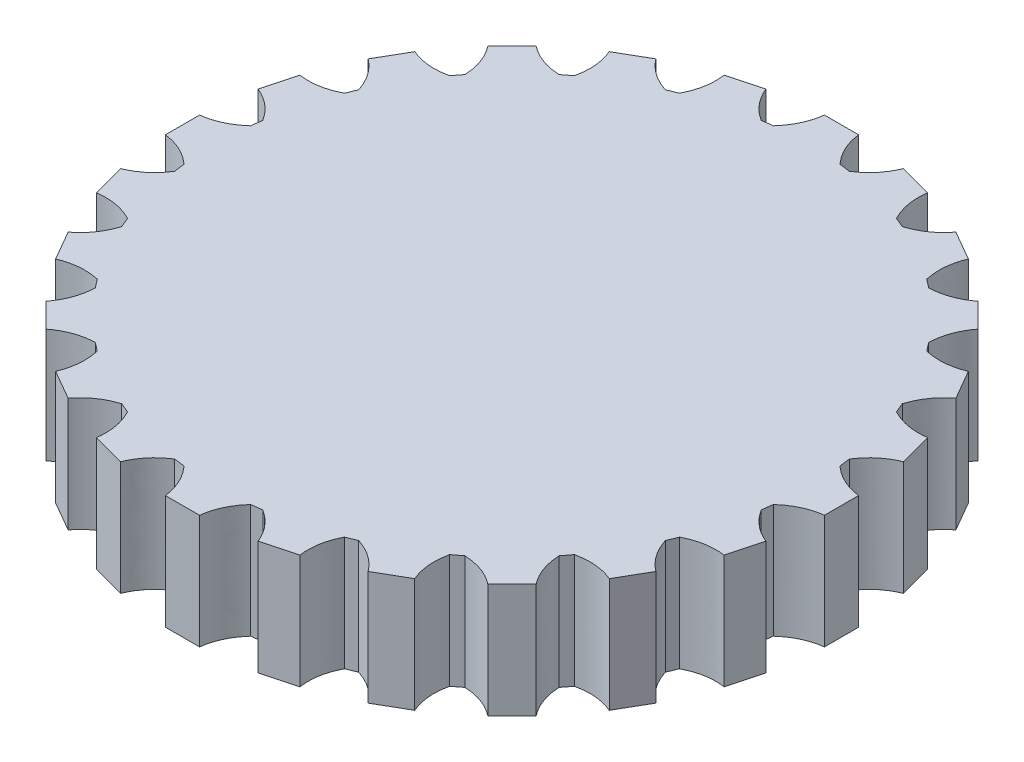
from build123d import *

# Parameters (mm, degrees)
BOSS_EXTRUDE2_DEPTH = 1.5
SKETCH3_R           = 3.8
CUT_EXTRUDE1_DEPTH  = 1.3


with BuildPart() as part:
    # Sketch2 → Boss-Extrude2 (new body)
    with BuildSketch(Plane(origin=(0, 0, 0), x_dir=(1, 0, 0), z_dir=(0, 1, 0))):
        with BuildLine():
            Line((0.224673315, 4.334046599), (-0.224673315, 4.334046599))
            add(Edge.make_bspline(
                [(-0.437962601, 3.875330794), (-0.256985034, 4.073833314), (-0.224673315, 4.334046599)],
                knots=[0, 0, 0, 1, 1, 1], degree=2))
            ThreePointArc((-0.437962601, 3.875330794), (-0.50905215, 3.866634959), (-0.579970028, 3.856635161))
            add(Edge.make_bspline(
                [(-0.579970028, 3.856635161), (-0.806157167, 4.001533431), (-0.904716044, 4.244517276)],
                knots=[0, 0, 0, 1, 1, 1], degree=2))
            Line((-0.904716044, 4.244517276), (-1.33875156, 4.12821781))
            add(Edge.make_bspline(
                [(-1.426048803, 3.629929037), (-1.302614129, 3.868508189), (-1.33875156, 4.12821781)],
                knots=[0, 0, 0, 1, 1, 1], degree=2))
            ThreePointArc((-1.426048803, 3.629929037), (-1.492465386, 3.603130177), (-1.558378658, 3.575116216))
            add(Edge.make_bspline(
                [(-1.558378658, 3.575116216), (-1.814361089, 3.656535658), (-1.972450501, 3.865731114)],
                knots=[0, 0, 0, 1, 1, 1], degree=2))
            Line((-1.972450501, 3.865731114), (-2.361596098, 3.641057799))
            add(Edge.make_bspline(
                [(-2.316952135, 3.137153615), (-2.259472225, 3.399550624), (-2.361596098, 3.641057799)],
                knots=[0, 0, 0, 1, 1, 1], degree=2))
            ThreePointArc((-2.316952135, 3.137153615), (-2.374169573, 3.094078027), (-2.430586358, 3.049959009))
            add(Edge.make_bspline(
                [(-2.430586358, 3.049959009), (-2.698919302, 3.062351022), (-2.905765716, 3.223501765)],
                knots=[0, 0, 0, 1, 1, 1], degree=2))
            Line((-2.905765716, 3.223501765), (-3.223501765, 2.905765716))
            add(Edge.make_bspline(
                [(-3.049959009, 2.430586358), (-3.062351022, 2.698919302), (-3.223501765, 2.905765716)],
                knots=[0, 0, 0, 1, 1, 1], degree=2))
            ThreePointArc((-3.049959009, 2.430586358), (-3.094078027, 2.374169573), (-3.137153615, 2.316952135))
            add(Edge.make_bspline(
                [(-3.137153615, 2.316952135), (-3.399550624, 2.259472225), (-3.641057799, 2.361596098)],
                knots=[0, 0, 0, 1, 1, 1], degree=2))
            Line((-3.641057799, 2.361596098), (-3.865731114, 1.972450501))
            add(Edge.make_bspline(
                [(-3.575116216, 1.558378658), (-3.656535658, 1.814361089), (-3.865731114, 1.972450501)],
                knots=[0, 0, 0, 1, 1, 1], degree=2))
            ThreePointArc((-3.575116216, 1.558378658), (-3.603130177, 1.492465386), (-3.629929037, 1.426048803))
            add(Edge.make_bspline(
                [(-3.629929037, 1.426048803), (-3.868508189, 1.302614129), (-4.12821781, 1.33875156)],
                knots=[0, 0, 0, 1, 1, 1], degree=2))
            Line((-4.12821781, 1.33875156), (-4.244517276, 0.904716044))
            add(Edge.make_bspline(
                [(-3.856635161, 0.579970028), (-4.001533431, 0.806157167), (-4.244517276, 0.904716044)],
                knots=[0, 0, 0, 1, 1, 1], degree=2))
            ThreePointArc((-3.856635161, 0.579970028), (-3.866634959, 0.50905215), (-3.875330794, 0.437962601))
            add(Edge.make_bspline(
                [(-3.875330794, 0.437962601), (-4.073833314, 0.256985034), (-4.334046599, 0.224673315)],
                knots=[0, 0, 0, 1, 1, 1], degree=2))
            Line((-4.334046599, 0.224673315), (-4.334046599, -0.224673315))
            add(Edge.make_bspline(
                [(-3.875330794, -0.437962601), (-4.073833314, -0.256985034), (-4.334046599, -0.224673315)],
                knots=[0, 0, 0, 1, 1, 1], degree=2))
            ThreePointArc((-3.875330794, -0.437962601), (-3.866634959, -0.50905215), (-3.856635161, -0.579970028))
            add(Edge.make_bspline(
                [(-3.856635161, -0.579970028), (-4.001533431, -0.806157167), (-4.244517276, -0.904716044)],
                knots=[0, 0, 0, 1, 1, 1], degree=2))
            Line((-4.244517276, -0.904716044), (-4.12821781, -1.33875156))
            add(Edge.make_bspline(
                [(-3.629929037, -1.426048803), (-3.868508189, -1.302614129), (-4.12821781, -1.33875156)],
                knots=[0, 0, 0, 1, 1, 1], degree=2))
            ThreePointArc((-3.629929037, -1.426048803), (-3.603130177, -1.492465386), (-3.575116216, -1.558378658))
            add(Edge.make_bspline(
                [(-3.575116216, -1.558378658), (-3.656535658, -1.814361089), (-3.865731114, -1.972450501)],
                knots=[0, 0, 0, 1, 1, 1], degree=2))
            Line((-3.865731114, -1.972450501), (-3.641057799, -2.361596098))
            add(Edge.make_bspline(
                [(-3.137153615, -2.316952135), (-3.399550624, -2.259472225), (-3.641057799, -2.361596098)],
                knots=[0, 0, 0, 1, 1, 1], degree=2))
            ThreePointArc((-3.137153615, -2.316952135), (-3.094078027, -2.374169573), (-3.049959009, -2.430586358))
            add(Edge.make_bspline(
                [(-3.049959009, -2.430586358), (-3.062351022, -2.698919302), (-3.223501765, -2.905765716)],
                knots=[0, 0, 0, 1, 1, 1], degree=2))
            Line((-3.223501765, -2.905765716), (-2.905765716, -3.223501765))
            add(Edge.make_bspline(
                [(-2.430586358, -3.049959009), (-2.698919302, -3.062351022), (-2.905765716, -3.223501765)],
                knots=[0, 0, 0, 1, 1, 1], degree=2))
            ThreePointArc((-2.430586358, -3.049959009), (-2.374169573, -3.094078027), (-2.316952135, -3.137153615))
            add(Edge.make_bspline(
                [(-2.316952135, -3.137153615), (-2.259472225, -3.399550624), (-2.361596098, -3.641057799)],
                knots=[0, 0, 0, 1, 1, 1], degree=2))
            Line((-2.361596098, -3.641057799), (-1.972450501, -3.865731114))
            add(Edge.make_bspline(
                [(-1.558378658, -3.575116216), (-1.814361089, -3.656535658), (-1.972450501, -3.865731114)],
                knots=[0, 0, 0, 1, 1, 1], degree=2))
            ThreePointArc((-1.558378658, -3.575116216), (-1.492465386, -3.603130177), (-1.426048803, -3.629929037))
            add(Edge.make_bspline(
                [(-1.426048803, -3.629929037), (-1.302614129, -3.868508189), (-1.33875156, -4.12821781)],
                knots=[0, 0, 0, 1, 1, 1], degree=2))
            Line((-1.33875156, -4.12821781), (-0.904716044, -4.244517276))
            add(Edge.make_bspline(
                [(-0.579970028, -3.856635161), (-0.806157167, -4.001533431), (-0.904716044, -4.244517276)],
                knots=[0, 0, 0, 1, 1, 1], degree=2))
            ThreePointArc((-0.579970028, -3.856635161), (-0.50905215, -3.866634959), (-0.437962601, -3.875330794))
            add(Edge.make_bspline(
                [(-0.437962601, -3.875330794), (-0.256985034, -4.073833314), (-0.224673315, -4.334046599)],
                knots=[0, 0, 0, 1, 1, 1], degree=2))
            Line((-0.224673315, -4.334046599), (0.224673315, -4.334046599))
            add(Edge.make_bspline(
                [(0.437962601, -3.875330794), (0.256985034, -4.073833314), (0.224673315, -4.334046599)],
                knots=[0, 0, 0, 1, 1, 1], degree=2))
            ThreePointArc((0.437962601, -3.875330794), (0.50905215, -3.866634959), (0.579970028, -3.856635161))
            add(Edge.make_bspline(
                [(0.579970028, -3.856635161), (0.806157167, -4.001533431), (0.904716044, -4.244517276)],
                knots=[0, 0, 0, 1, 1, 1], degree=2))
            Line((0.904716044, -4.244517276), (1.33875156, -4.12821781))
            add(Edge.make_bspline(
                [(1.426048803, -3.629929037), (1.302614129, -3.868508189), (1.33875156, -4.12821781)],
                knots=[0, 0, 0, 1, 1, 1], degree=2))
            ThreePointArc((1.426048803, -3.629929037), (1.492465386, -3.603130177), (1.558378658, -3.575116216))
            add(Edge.make_bspline(
                [(1.558378658, -3.575116216), (1.814361089, -3.656535658), (1.972450501, -3.865731114)],
                knots=[0, 0, 0, 1, 1, 1], degree=2))
            Line((1.972450501, -3.865731114), (2.361596098, -3.641057799))
            add(Edge.make_bspline(
                [(2.316952135, -3.137153615), (2.259472225, -3.399550624), (2.361596098, -3.641057799)],
                knots=[0, 0, 0, 1, 1, 1], degree=2))
            ThreePointArc((2.316952135, -3.137153615), (2.374169573, -3.094078027), (2.430586358, -3.049959009))
            add(Edge.make_bspline(
                [(2.430586358, -3.049959009), (2.698919302, -3.062351022), (2.905765716, -3.223501765)],
                knots=[0, 0, 0, 1, 1, 1], degree=2))
            Line((2.905765716, -3.223501765), (3.223501765, -2.905765716))
            add(Edge.make_bspline(
                [(3.049959009, -2.430586358), (3.062351022, -2.698919302), (3.223501765, -2.905765716)],
                knots=[0, 0, 0, 1, 1, 1], degree=2))
            ThreePointArc((3.049959009, -2.430586358), (3.094078027, -2.374169573), (3.137153615, -2.316952135))
            add(Edge.make_bspline(
                [(3.137153615, -2.316952135), (3.399550624, -2.259472225), (3.641057799, -2.361596098)],
                knots=[0, 0, 0, 1, 1, 1], degree=2))
            Line((3.641057799, -2.361596098), (3.865731114, -1.972450501))
            add(Edge.make_bspline(
                [(3.575116216, -1.558378658), (3.656535658, -1.814361089), (3.865731114, -1.972450501)],
                knots=[0, 0, 0, 1, 1, 1], degree=2))
            ThreePointArc((3.575116216, -1.558378658), (3.603130177, -1.492465386), (3.629929037, -1.426048803))
            add(Edge.make_bspline(
                [(3.629929037, -1.426048803), (3.868508189, -1.302614129), (4.12821781, -1.33875156)],
                knots=[0, 0, 0, 1, 1, 1], degree=2))
            Line((4.12821781, -1.33875156), (4.244517276, -0.904716044))
            add(Edge.make_bspline(
                [(3.856635161, -0.579970028), (4.001533431, -0.806157167), (4.244517276, -0.904716044)],
                knots=[0, 0, 0, 1, 1, 1], degree=2))
            ThreePointArc((3.856635161, -0.579970028), (3.866634959, -0.50905215), (3.875330794, -0.437962601))
            add(Edge.make_bspline(
                [(3.875330794, -0.437962601), (4.073833314, -0.256985034), (4.334046599, -0.224673315)],
                knots=[0, 0, 0, 1, 1, 1], degree=2))
            Line((4.334046599, -0.224673315), (4.334046599, 0.224673315))
            add(Edge.make_bspline(
                [(3.875330794, 0.437962601), (4.073833314, 0.256985034), (4.334046599, 0.224673315)],
                knots=[0, 0, 0, 1, 1, 1], degree=2))
            ThreePointArc((3.875330794, 0.437962601), (3.866634959, 0.50905215), (3.856635161, 0.579970028))
            add(Edge.make_bspline(
                [(3.856635161, 0.579970028), (4.001533431, 0.806157167), (4.244517276, 0.904716044)],
                knots=[0, 0, 0, 1, 1, 1], degree=2))
            Line((4.244517276, 0.904716044), (4.12821781, 1.33875156))
            add(Edge.make_bspline(
                [(3.629929037, 1.426048803), (3.868508189, 1.302614129), (4.12821781, 1.33875156)],
                knots=[0, 0, 0, 1, 1, 1], degree=2))
            ThreePointArc((3.629929037, 1.426048803), (3.603130177, 1.492465386), (3.575116216, 1.558378658))
            add(Edge.make_bspline(
                [(3.575116216, 1.558378658), (3.656535658, 1.814361089), (3.865731114, 1.972450501)],
                knots=[0, 0, 0, 1, 1, 1], degree=2))
            Line((3.865731114, 1.972450501), (3.641057799, 2.361596098))
            add(Edge.make_bspline(
                [(3.137153615, 2.316952135), (3.399550624, 2.259472225), (3.641057799, 2.361596098)],
                knots=[0, 0, 0, 1, 1, 1], degree=2))
            ThreePointArc((3.137153615, 2.316952135), (3.094078027, 2.374169573), (3.049959009, 2.430586358))
            add(Edge.make_bspline(
                [(3.049959009, 2.430586358), (3.062351022, 2.698919302), (3.223501765, 2.905765716)],
                knots=[0, 0, 0, 1, 1, 1], degree=2))
            Line((3.223501765, 2.905765716), (2.905765716, 3.223501765))
            add(Edge.make_bspline(
                [(2.430586358, 3.049959009), (2.698919302, 3.062351022), (2.905765716, 3.223501765)],
                knots=[0, 0, 0, 1, 1, 1], degree=2))
            ThreePointArc((2.430586358, 3.049959009), (2.374169573, 3.094078027), (2.316952135, 3.137153615))
            add(Edge.make_bspline(
                [(2.316952135, 3.137153615), (2.259472225, 3.399550624), (2.361596098, 3.641057799)],
                knots=[0, 0, 0, 1, 1, 1], degree=2))
            Line((2.361596098, 3.641057799), (1.972450501, 3.865731114))
            add(Edge.make_bspline(
                [(1.558378658, 3.575116216), (1.814361089, 3.656535658), (1.972450501, 3.865731114)],
                knots=[0, 0, 0, 1, 1, 1], degree=2))
            ThreePointArc((1.558378658, 3.575116216), (1.492465386, 3.603130177), (1.426048803, 3.629929037))
            add(Edge.make_bspline(
                [(1.426048803, 3.629929037), (1.302614129, 3.868508189), (1.33875156, 4.12821781)],
                knots=[0, 0, 0, 1, 1, 1], degree=2))
            Line((1.33875156, 4.12821781), (0.904716044, 4.244517276))
            add(Edge.make_bspline(
                [(0.579970028, 3.856635161), (0.806157167, 4.001533431), (0.904716044, 4.244517276)],
                knots=[0, 0, 0, 1, 1, 1], degree=2))
            ThreePointArc((0.579970028, 3.856635161), (0.50905215, 3.866634959), (0.437962601, 3.875330794))
            add(Edge.make_bspline(
                [(0.437962601, 3.875330794), (0.256985034, 4.073833314), (0.224673315, 4.334046599)],
                knots=[0, 0, 0, 1, 1, 1], degree=2))
        make_face()
    extrude(amount=-BOSS_EXTRUDE2_DEPTH)

    # Sketch3 → Cut-Extrude1 (cut)
    with BuildSketch(Plane.XZ.offset(1.5)):
        Circle(SKETCH3_R)
    extrude(amount=-CUT_EXTRUDE1_DEPTH, mode=Mode.SUBTRACT)


solid = part.part
